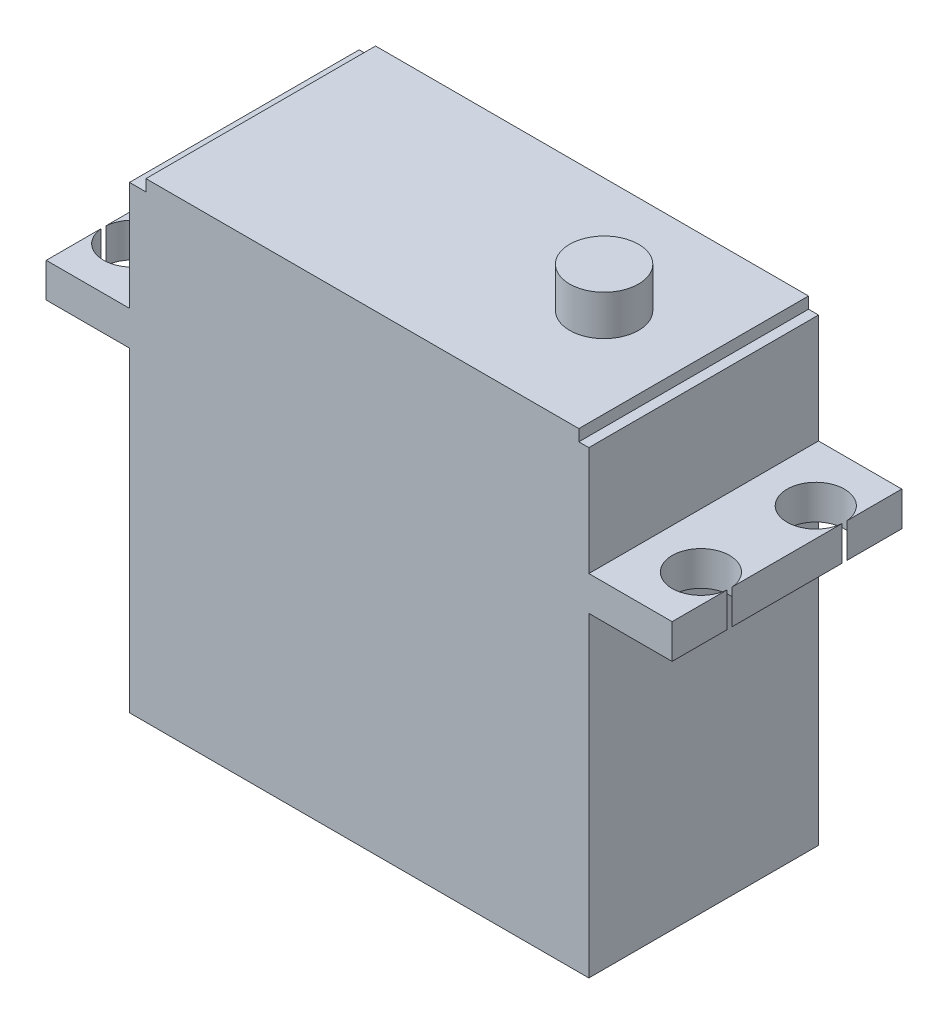
from build123d import *

# Parameters (mm, degrees)
EXTRUDE_1_DEPTH     = 20
SKETCH_2_R          = 2.5
CUT_EXTRUDE_4_DEPTH = 20
SKETCH_3_W          = 37.700616616
SKETCH_3_H          = 20
EXTRUDE_3_DEPTH     = 1
SKETCH_4_R          = 3
EXTRUDE_4_DEPTH     = 3.5


with BuildPart() as part:
    # 草图1 → 凸台-拉伸1 (new body)
    with BuildSketch(Plane.XY):
        Polygon((20, 0), (-20, 0), (-20, 27.5), (-27.25, 27.5), (-27.25, 30.5), (-20, 30.5), (-20, 40), (20, 40), (20, 30.5), (27.25, 30.5), (27.25, 27.5), (20, 27.5), align=None)
    extrude(amount=-EXTRUDE_1_DEPTH)

    # 草图2 → 切除-拉伸4 (cut)
    with BuildSketch(Plane(origin=(0, 30.5, 0), x_dir=(1, 0, 0), z_dir=(0, 1, 0))):
        with Locations((-24.76, 15)):
            Circle(SKETCH_2_R)
        with Locations((-24.76, 5)):
            Circle(SKETCH_2_R)
        with Locations((24.76, 5)):
            Circle(SKETCH_2_R)
        with Locations((24.76, 15)):
            Circle(SKETCH_2_R)
    extrude(amount=-CUT_EXTRUDE_4_DEPTH, mode=Mode.SUBTRACT)

    # 草图3 → 凸台-拉伸3 (add)
    with BuildSketch(Plane(origin=(0, 40, 0), x_dir=(1, 0, 0), z_dir=(0, 1, 0))):
        with Locations((0.280093734, 10)):
            Rectangle(SKETCH_3_W, SKETCH_3_H)
    extrude(amount=EXTRUDE_3_DEPTH)

    # 草图4 → 凸台-拉伸4 (add)
    with BuildSketch(Plane(origin=(0, 41, 0), x_dir=(1, 0, 0), z_dir=(0, 1, 0))):
        with Locations((11.329785426, 10)):
            Circle(SKETCH_4_R)
    extrude(amount=EXTRUDE_4_DEPTH)


solid = part.part
